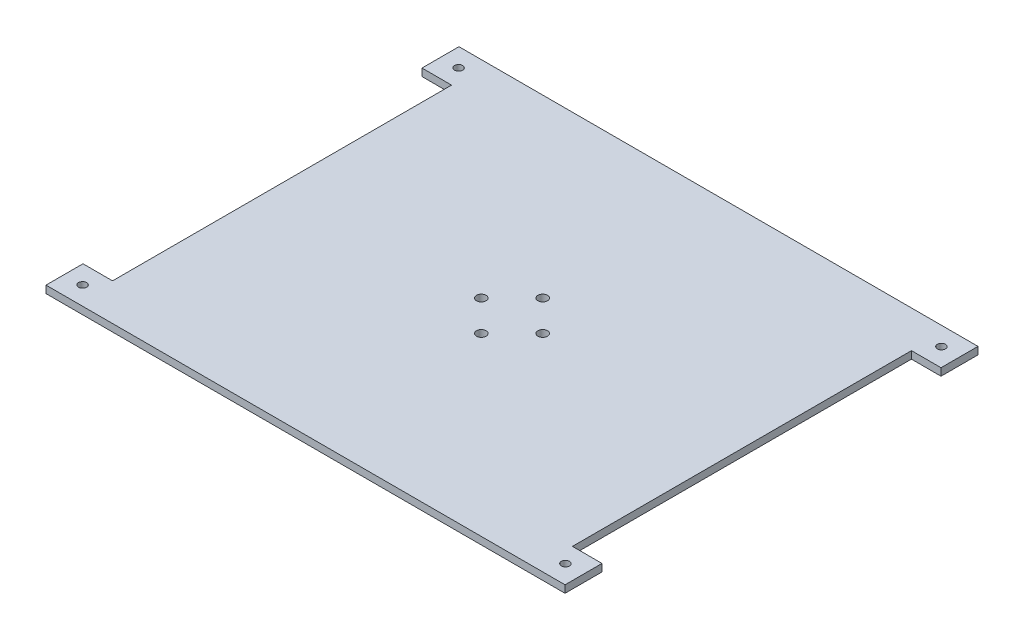
from build123d import *

# Parameters (mm, degrees)
BOSS_EXTRUDE1_DEPTH = 2
SKETCH2_R           = 1.1
CUT_EXTRUDE1_DEPTH  = 2
SKETCH3_R           = 1.3
CUT_EXTRUDE2_DEPTH  = 2


with BuildPart() as part:
    # Sketch1 → Boss-Extrude1 (new body)
    with BuildSketch(Plane(origin=(0, 0, 0), x_dir=(1, 0, 0), z_dir=(0, 1, 0))):
        Polygon((-53.749139255, 17.446368981), (-45.749139255, 17.446368981), (-45.749139255, -74.253631019), (-53.749139255, -74.253631019), (-53.749139255, -84.253631019), (86.650860745, -84.253631019), (86.650860745, -74.253631019), (78.650860745, -74.253631019), (78.650860745, 17.446368981), (86.650860745, 17.446368981), (86.650860745, 27.446368981), (-53.749139255, 27.446368981), align=None)
    extrude(amount=BOSS_EXTRUDE1_DEPTH)

    # Sketch2 → Cut-Extrude1 (cut)
    with BuildSketch(Plane(origin=(0, 2, 0), x_dir=(1, 0, 0), z_dir=(0, 1, 0))):
        with Locations((-48.849139255, -79.253631019)):
            Circle(SKETCH2_R)
        with Locations((-48.849139255, 22.446368981)):
            Circle(SKETCH2_R)
        with Locations((81.750860745, 22.446368981)):
            Circle(SKETCH2_R)
        with Locations((81.750860745, -79.253631019)):
            Circle(SKETCH2_R)
    extrude(amount=-CUT_EXTRUDE1_DEPTH, mode=Mode.SUBTRACT)

    # Sketch3 → Cut-Extrude2 (cut)
    with BuildSketch(Plane(origin=(0, 2, 0), x_dir=(1, 0, 0), z_dir=(0, 1, 0))):
        with Locations((8.150860745, -28.403631019)):
            Circle(SKETCH3_R)
        with Locations((16.450860745, -36.703631019)):
            Circle(SKETCH3_R)
        with Locations((24.750860745, -28.403631019)):
            Circle(SKETCH3_R)
        with Locations((16.450860745, -20.103631019)):
            Circle(SKETCH3_R)
    extrude(amount=-CUT_EXTRUDE2_DEPTH, mode=Mode.SUBTRACT)


solid = part.part
